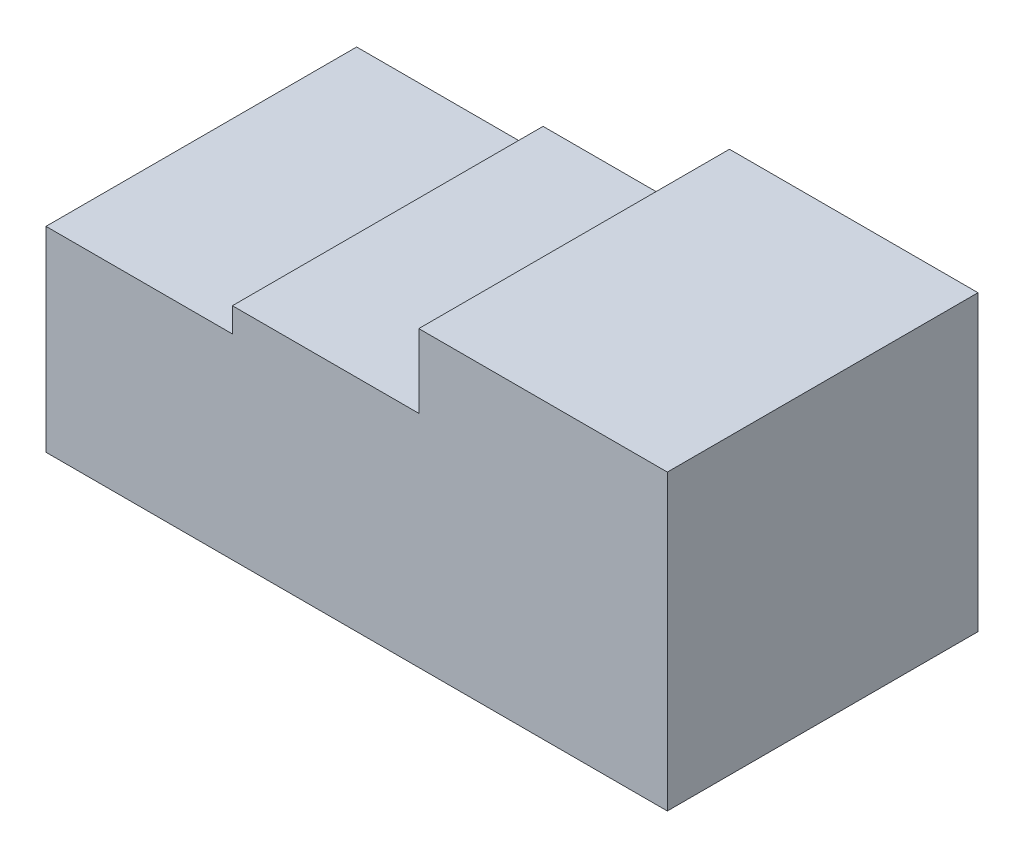
from build123d import *

# Parameters (mm, degrees)
BOSS_EXTRUDE1_DEPTH = 25.4
CUT_EXTRUDE1_DEPTH  = 4


with BuildPart() as part:
    # Sketch1 → Boss-Extrude1 (new body)
    with BuildSketch(Plane.XY):
        Polygon((0, 0), (50.8, 0), (50.8, 24), (30.48, 24), (30.48, 18), (15.24, 18), (15.24, 16), (0, 16), align=None)
    extrude(amount=BOSS_EXTRUDE1_DEPTH)

    # Sketch2 → Cut-Extrude1 (cut)
    with BuildSketch(Plane(origin=(0, 0, 0), x_dir=(-1, 0, 0), z_dir=(0, 0, -1))):
        with BuildLine():
            Line((-11.295583304, 12.778087276), (-11.533029885, 12.778087276))
            add(Edge.make_bspline(
                [(-11.533029885, 12.778087276), (-11.531572522, 12.809575531), (-11.528713289, 12.871353046), (-11.516252525, 12.961529656), (-11.498058527, 13.047711984), (-11.471773606, 13.129079663), (-11.439991974, 13.206785318), (-11.401253164, 13.279890085), (-11.355949163, 13.348858041), (-11.304136805, 13.412465116), (-11.247954919, 13.47053484), (-11.18779932, 13.52151142), (-11.123831636, 13.563773065), (-11.057192589, 13.599493121), (-10.986884509, 13.626239523), (-10.913640661, 13.646190792), (-10.836980782, 13.658076885), (-10.78469055, 13.659373545), (-10.758148408, 13.66003172)],
                knots=[0, 0, 0, 0, 9.4523e-05, 0.000185446, 0.000272771, 0.000358426, 0.000441598, 0.000524343, 0.000606223, 0.00068875, 0.000770085, 0.00084833, 0.000924769, 0.000999689, 0.001074691, 0.001149905, 0.001227113, 0.001306701, 0.001306701, 0.001306701, 0.001306701], degree=3))
            add(Edge.make_bspline(
                [(-10.758148408, 13.66003172), (-10.731960548, 13.659353685), (-10.68075122, 13.658027815), (-10.605918747, 13.646621805), (-10.535108463, 13.627947117), (-10.467619701, 13.602640908), (-10.404252866, 13.568846187), (-10.344773135, 13.527866845), (-10.288939132, 13.479696149), (-10.23838045, 13.424133521), (-10.191934607, 13.364315847), (-10.151617833, 13.300822017), (-10.116730428, 13.235148299), (-10.089311606, 13.166208706), (-10.067526922, 13.094945266), (-10.051368254, 13.021090543), (-10.042459589, 12.944378809), (-10.041164921, 12.892415422), (-10.040508518, 12.866069714)],
                knots=[0, 0, 0, 0, 7.853e-05, 0.000153562, 0.000226454, 0.000297918, 0.000369283, 0.00044132, 0.000514216, 0.00058998, 0.00066631, 0.000741147, 0.000815351, 0.000889069, 0.000963341, 0.001038709, 0.001115561, 0.001194597, 0.001194597, 0.001194597, 0.001194597], degree=3))
            add(Edge.make_bspline(
                [(-10.040508518, 12.866069714), (-10.041600283, 12.828898688), (-10.043759812, 12.75537383), (-10.06186439, 12.647089025), (-10.091127397, 12.542404939), (-10.125567065, 12.457517477), (-10.160444917, 12.388910391), (-10.192162361, 12.333062131), (-10.229680183, 12.273032827), (-10.272096757, 12.208237561), (-10.320151973, 12.139119815), (-10.374110374, 12.065918137), (-10.43269698, 11.987842672), (-10.47463475, 11.935084753), (-10.496321151, 11.907803155)],
                knots=[0, 0, 0, 0, 0.000111456, 0.000220461, 0.000328356, 0.000437015, 0.000494613, 0.000559171, 0.000629623, 0.000706947, 0.000791487, 0.000882126, 0.000979755, 0.001084302, 0.001084302, 0.001084302, 0.001084302], degree=3))
            Line((-10.496321151, 11.907803155), (-11.057076694, 11.217724028))
            Line((-11.057076694, 11.217724028), (-10.006587578, 11.217724028))
            Line((-10.006587578, 11.217724028), (-10.006587578, 10.946356507))
            Line((-10.006587578, 10.946356507), (-11.600871766, 10.946356507))
            Line((-11.600871766, 10.946356507), (-10.711507116, 12.041366857))
            add(Edge.make_bspline(
                [(-10.711507116, 12.041366857), (-10.689889178, 12.067461588), (-10.648310171, 12.117651067), (-10.589446671, 12.190781158), (-10.536471996, 12.258650576), (-10.488923601, 12.320987829), (-10.448459073, 12.37880704), (-10.412977585, 12.430799132), (-10.383874899, 12.477880644), (-10.352677075, 12.533205057), (-10.322859658, 12.600627754), (-10.296292224, 12.682346992), (-10.281243445, 12.76675858), (-10.279057625, 12.823612348), (-10.277955099, 12.852289332)],
                knots=[0, 0, 0, 0, 0.000101658, 0.000195524, 0.000281615, 0.000359952, 0.000430685, 0.000493307, 0.000548759, 0.000596686, 0.000683759, 0.000769413, 0.000853939, 0.000939964, 0.000939964, 0.000939964, 0.000939964], degree=3))
            add(Edge.make_bspline(
                [(-10.277955099, 12.852289332), (-10.278300298, 12.870334022), (-10.278979807, 12.905854207), (-10.286201362, 12.957984673), (-10.29734004, 13.008161489), (-10.312674236, 13.056705441), (-10.332798191, 13.103194264), (-10.357460674, 13.147764754), (-10.386871816, 13.190111323), (-10.419756558, 13.230595612), (-10.456162818, 13.267473966), (-10.494798891, 13.300131193), (-10.535915275, 13.327124737), (-10.57873842, 13.349822092), (-10.623730969, 13.367310401), (-10.670728194, 13.379374645), (-10.719554516, 13.387137812), (-10.752818161, 13.388148139), (-10.769808732, 13.388664199)],
                knots=[0, 0, 0, 0, 5.4103e-05, 0.0001065, 0.000157549, 0.00020817, 0.000258974, 0.00030927, 0.000360725, 0.000413456, 0.000465551, 0.000515972, 0.000564923, 0.000612812, 0.00066114, 0.000709348, 0.000758147, 0.000809097, 0.000809097, 0.000809097, 0.000809097], degree=3))
            add(Edge.make_bspline(
                [(-10.769808732, 13.388664199), (-10.787500652, 13.388123771), (-10.822335055, 13.387059699), (-10.873542848, 13.379570538), (-10.922401386, 13.36686802), (-10.96898922, 13.348997667), (-11.013648099, 13.327153673), (-11.055409027, 13.29880625), (-11.095110374, 13.266095738), (-11.13213107, 13.228364109), (-11.16621748, 13.18642825), (-11.196444173, 13.140011166), (-11.223038496, 13.089674595), (-11.245042687, 13.034977559), (-11.264647474, 12.976780446), (-11.278142964, 12.913913307), (-11.28992575, 12.847511354), (-11.293664514, 12.801632832), (-11.295583304, 12.778087276)],
                knots=[0, 0, 0, 0, 5.3068e-05, 0.000104487, 0.000154881, 0.000204198, 0.000253974, 0.00030366, 0.000355235, 0.00040808, 0.000461967, 0.000517093, 0.000573993, 0.000632458, 0.000693803, 0.000757961, 0.000825141, 0.000895969, 0.000895969, 0.000895969, 0.000895969], degree=3))
        make_face()
        with BuildLine():
            Line((-9.212837578, 12.879850096), (-8.975390997, 12.879850096))
            Line((-8.975390997, 12.879850096), (-8.975390997, 12.543820783))
            add(Edge.make_bspline(
                [(-8.975390997, 12.543820783), (-8.956794863, 12.573133728), (-8.921396056, 12.628932602), (-8.86334048, 12.703336958), (-8.805369343, 12.76630988), (-8.76293803, 12.799770446), (-8.742714548, 12.815718319)],
                knots=[0, 0, 0, 0, 0.000104077, 0.000198117, 0.000282847, 0.000360005, 0.000360005, 0.000360005, 0.000360005], degree=3))
            add(Edge.make_bspline(
                [(-8.742714548, 12.815718319), (-8.715341212, 12.830802884), (-8.661452156, 12.86049941), (-8.575012152, 12.891277549), (-8.486453749, 12.909838039), (-8.426560003, 12.912460091), (-8.396614955, 12.913771037)],
                knots=[0, 0, 0, 0, 9.3634e-05, 0.000184335, 0.000274144, 0.000363942, 0.000363942, 0.000363942, 0.000363942], degree=3))
            add(Edge.make_bspline(
                [(-8.396614955, 12.913771037), (-8.376436106, 12.912978178), (-8.336361145, 12.911403571), (-8.276845975, 12.901149854), (-8.219046141, 12.883587769), (-8.163490475, 12.859141435), (-8.111433351, 12.829017948), (-8.063281018, 12.794641861), (-8.020511278, 12.755134056), (-7.982695588, 12.709921892), (-7.947914792, 12.657930518), (-7.917233461, 12.596389434), (-7.887756651, 12.525440703), (-7.87148733, 12.474007075), (-7.862890162, 12.446828095)],
                knots=[0, 0, 0, 0, 6.0535e-05, 0.000120223, 0.000180584, 0.000241342, 0.000301889, 0.00036073, 0.000418489, 0.000476037, 0.000537189, 0.000605694, 0.000681976, 0.000767454, 0.000767454, 0.000767454, 0.000767454], degree=3))
            add(Edge.make_bspline(
                [(-7.862890162, 12.446828095), (-7.853733646, 12.465487304), (-7.835790121, 12.502052738), (-7.805821282, 12.554110694), (-7.774736964, 12.602909572), (-7.741736659, 12.648313537), (-7.706832704, 12.689915472), (-7.670597484, 12.728556798), (-7.632529649, 12.763495077), (-7.580053264, 12.804673494), (-7.511506355, 12.848069456), (-7.42462161, 12.886162824), (-7.334093444, 12.909555469), (-7.272588507, 12.912362103), (-7.241712945, 12.913771037)],
                knots=[0, 0, 0, 0, 6.2339e-05, 0.000122163, 0.00018009, 0.000235852, 0.000290413, 0.000342903, 0.000394671, 0.000445248, 0.000542892, 0.000637124, 0.000728907, 0.000821428, 0.000821428, 0.000821428, 0.000821428], degree=3))
            add(Edge.make_bspline(
                [(-7.241712945, 12.913771037), (-7.213348741, 12.912536714), (-7.1575831, 12.910109966), (-7.076395577, 12.891243943), (-7.000828388, 12.858848766), (-6.93110531, 12.814565774), (-6.868239825, 12.759187197), (-6.813920596, 12.693146875), (-6.767682626, 12.617486169), (-6.737905279, 12.546393548), (-6.717480464, 12.483563244), (-6.704532977, 12.430014174), (-6.693358447, 12.370934135), (-6.684749698, 12.306317237), (-6.676946357, 12.23620271), (-6.67274887, 12.160303458), (-6.669266146, 12.078853329), (-6.66893684, 12.022644258), (-6.668767065, 11.993665534)],
                knots=[0, 0, 0, 0, 8.5041e-05, 0.000167195, 0.000248411, 0.000330606, 0.000413972, 0.000498663, 0.000586199, 0.000679038, 0.000729155, 0.000784302, 0.000844177, 0.000909464, 0.000979818, 0.00105576, 0.001137444, 0.001224373, 0.001224373, 0.001224373, 0.001224373], degree=3))
            Line((-6.668767065, 11.993665534), (-6.668767065, 10.946356507))
            Line((-6.668767065, 10.946356507), (-6.906213646, 10.946356507))
            Line((-6.906213646, 10.946356507), (-6.906213646, 11.994725564))
            add(Edge.make_bspline(
                [(-6.906213646, 11.994725564), (-6.906323922, 12.019459768), (-6.906535835, 12.066990354), (-6.907895866, 12.135215362), (-6.911201131, 12.197409514), (-6.915274704, 12.253447893), (-6.920583511, 12.303470184), (-6.926647684, 12.347584604), (-6.934486566, 12.385644655), (-6.94632021, 12.427888082), (-6.965277061, 12.474283423), (-6.993540202, 12.52499537), (-7.03057646, 12.56865378), (-7.072705078, 12.607181187), (-7.12115953, 12.637925739), (-7.17441099, 12.660599309), (-7.232383819, 12.674152829), (-7.272557976, 12.675589155), (-7.29312437, 12.676324455)],
                knots=[0, 0, 0, 0, 7.4204e-05, 0.000142594, 0.000204688, 0.000261029, 0.000311131, 0.00035558, 0.00039456, 0.000427613, 0.00048706, 0.000544517, 0.000600978, 0.000658023, 0.000715218, 0.000772216, 0.000830971, 0.000892599, 0.000892599, 0.000892599, 0.000892599], degree=3))
            add(Edge.make_bspline(
                [(-7.29312437, 12.676324455), (-7.31835614, 12.675205627), (-7.368760594, 12.672970592), (-7.442062722, 12.651553709), (-7.512361665, 12.618349634), (-7.577347671, 12.571193799), (-7.637362534, 12.514442585), (-7.688536378, 12.446970825), (-7.731620204, 12.371322028), (-7.760118798, 12.301065578), (-7.778119859, 12.238059384), (-7.790227045, 12.182850773), (-7.800125402, 12.12019193), (-7.807819073, 12.050129329), (-7.814090775, 11.972712678), (-7.818918632, 11.887891904), (-7.821368935, 11.795631152), (-7.821836335, 11.731662799), (-7.822079031, 11.698447352)],
                knots=[0, 0, 0, 0, 7.553e-05, 0.000150884, 0.000227221, 0.000307811, 0.000390658, 0.000474193, 0.000560839, 0.000651191, 0.000700843, 0.000757296, 0.000820643, 0.000891056, 0.000968699, 0.001053635, 0.001145896, 0.001245544, 0.001245544, 0.001245544, 0.001245544], degree=3))
            Line((-7.822079031, 11.698447352), (-7.822079031, 10.946356507))
            Line((-7.822079031, 10.946356507), (-8.059525612, 10.946356507))
            Line((-8.059525612, 10.946356507), (-8.059525612, 11.929533757))
            add(Edge.make_bspline(
                [(-8.059525612, 11.929533757), (-8.059636013, 11.957271414), (-8.059848396, 12.010631616), (-8.061208209, 12.087156237), (-8.064486102, 12.156773514), (-8.068633125, 12.219335773), (-8.073749803, 12.274861778), (-8.080189574, 12.323462411), (-8.087051775, 12.365201937), (-8.099117964, 12.410866302), (-8.117764387, 12.460708), (-8.14634583, 12.514711133), (-8.182932637, 12.561799978), (-8.225999451, 12.602291257), (-8.274663903, 12.635073948), (-8.328121157, 12.659853106), (-8.386575312, 12.673504301), (-8.42693662, 12.675372705), (-8.447496365, 12.676324455)],
                knots=[0, 0, 0, 0, 8.3214e-05, 0.000160083, 0.000229587, 0.000292273, 0.000348176, 0.000396825, 0.000439348, 0.000474958, 0.000538356, 0.000598592, 0.000657536, 0.000716405, 0.000775206, 0.000832844, 0.000892236, 0.000953903, 0.000953903, 0.000953903, 0.000953903], degree=3))
            add(Edge.make_bspline(
                [(-8.447496365, 12.676324455), (-8.471840182, 12.675167813), (-8.520450463, 12.672858203), (-8.591624027, 12.651881364), (-8.660213005, 12.619019567), (-8.725577557, 12.574067271), (-8.785263505, 12.517824514), (-8.837524577, 12.452120179), (-8.881383168, 12.3773964), (-8.910463868, 12.308138804), (-8.929067008, 12.246684664), (-8.941938086, 12.194373202), (-8.9523179, 12.136111455), (-8.960507406, 12.072047975), (-8.967563679, 12.002256254), (-8.972142958, 11.926760161), (-8.974700016, 11.845279432), (-8.975154982, 11.789081766), (-8.975390997, 11.759929056)],
                knots=[0, 0, 0, 0, 7.289e-05, 0.000145548, 0.0002207, 0.000300381, 0.000382499, 0.000465853, 0.000551389, 0.000641655, 0.000690442, 0.000743919, 0.000803176, 0.000867866, 0.000937639, 0.001013581, 0.001094717, 0.001182176, 0.001182176, 0.001182176, 0.001182176], degree=3))
            Line((-8.975390997, 11.759929056), (-8.975390997, 10.946356507))
            Line((-8.975390997, 10.946356507), (-9.212837578, 10.946356507))
            Line((-9.212837578, 10.946356507), (-9.212837578, 12.879850096))
        make_face()
        with BuildLine():
            Line((-6.390615356, 12.879850096), (-6.153168774, 12.879850096))
            Line((-6.153168774, 12.879850096), (-6.153168774, 12.543820783))
            add(Edge.make_bspline(
                [(-6.153168774, 12.543820783), (-6.134572641, 12.573133728), (-6.099173834, 12.628932602), (-6.041118258, 12.703336958), (-5.983147121, 12.76630988), (-5.940715807, 12.799770446), (-5.920492325, 12.815718319)],
                knots=[0, 0, 0, 0, 0.000104077, 0.000198117, 0.000282847, 0.000360005, 0.000360005, 0.000360005, 0.000360005], degree=3))
            add(Edge.make_bspline(
                [(-5.920492325, 12.815718319), (-5.89311899, 12.830802884), (-5.839229934, 12.86049941), (-5.75278993, 12.891277549), (-5.664231527, 12.909838039), (-5.604337781, 12.912460091), (-5.574392733, 12.913771037)],
                knots=[0, 0, 0, 0, 9.3634e-05, 0.000184335, 0.000274144, 0.000363942, 0.000363942, 0.000363942, 0.000363942], degree=3))
            add(Edge.make_bspline(
                [(-5.574392733, 12.913771037), (-5.554213884, 12.912978178), (-5.514138923, 12.911403571), (-5.454623753, 12.901149854), (-5.396823918, 12.883587769), (-5.341268253, 12.859141435), (-5.289211129, 12.829017948), (-5.241058796, 12.794641861), (-5.198289056, 12.755134056), (-5.160473366, 12.709921892), (-5.12569257, 12.657930518), (-5.095011239, 12.596389434), (-5.065534429, 12.525440703), (-5.049265108, 12.474007075), (-5.04066794, 12.446828095)],
                knots=[0, 0, 0, 0, 6.0535e-05, 0.000120223, 0.000180584, 0.000241342, 0.000301889, 0.00036073, 0.000418489, 0.000476037, 0.000537189, 0.000605694, 0.000681976, 0.000767454, 0.000767454, 0.000767454, 0.000767454], degree=3))
            add(Edge.make_bspline(
                [(-5.04066794, 12.446828095), (-5.031511424, 12.465487304), (-5.013567899, 12.502052738), (-4.98359906, 12.554110694), (-4.952514742, 12.602909572), (-4.919514436, 12.648313537), (-4.884610482, 12.689915472), (-4.848375262, 12.728556798), (-4.810307427, 12.763495077), (-4.757831041, 12.804673494), (-4.689284133, 12.848069456), (-4.602399388, 12.886162824), (-4.511871222, 12.909555469), (-4.450366285, 12.912362103), (-4.419490723, 12.913771037)],
                knots=[0, 0, 0, 0, 6.2339e-05, 0.000122163, 0.00018009, 0.000235852, 0.000290413, 0.000342903, 0.000394671, 0.000445248, 0.000542892, 0.000637124, 0.000728907, 0.000821428, 0.000821428, 0.000821428, 0.000821428], degree=3))
            add(Edge.make_bspline(
                [(-4.419490723, 12.913771037), (-4.391126519, 12.912536714), (-4.335360878, 12.910109966), (-4.254173355, 12.891243943), (-4.178606166, 12.858848766), (-4.108883088, 12.814565774), (-4.046017603, 12.759187197), (-3.991698374, 12.693146875), (-3.945460404, 12.617486169), (-3.915683057, 12.546393548), (-3.895258242, 12.483563244), (-3.882310755, 12.430014174), (-3.871136225, 12.370934135), (-3.862527475, 12.306317237), (-3.854724135, 12.23620271), (-3.850526648, 12.160303458), (-3.847043924, 12.078853329), (-3.846714618, 12.022644258), (-3.846544843, 11.993665534)],
                knots=[0, 0, 0, 0, 8.5041e-05, 0.000167195, 0.000248411, 0.000330606, 0.000413972, 0.000498663, 0.000586199, 0.000679038, 0.000729155, 0.000784302, 0.000844177, 0.000909464, 0.000979818, 0.00105576, 0.001137444, 0.001224373, 0.001224373, 0.001224373, 0.001224373], degree=3))
            Line((-3.846544843, 11.993665534), (-3.846544843, 10.946356507))
            Line((-3.846544843, 10.946356507), (-4.083991424, 10.946356507))
            Line((-4.083991424, 10.946356507), (-4.083991424, 11.994725564))
            add(Edge.make_bspline(
                [(-4.083991424, 11.994725564), (-4.0841017, 12.019459768), (-4.084313613, 12.066990354), (-4.085673644, 12.135215362), (-4.088978909, 12.197409514), (-4.093052481, 12.253447893), (-4.098361288, 12.303470184), (-4.104425462, 12.347584604), (-4.112264344, 12.385644655), (-4.124097987, 12.427888082), (-4.143054839, 12.474283423), (-4.17131798, 12.52499537), (-4.208354238, 12.56865378), (-4.250482856, 12.607181187), (-4.298937308, 12.637925739), (-4.352188768, 12.660599309), (-4.410161597, 12.674152829), (-4.450335754, 12.675589155), (-4.470902148, 12.676324455)],
                knots=[0, 0, 0, 0, 7.4204e-05, 0.000142594, 0.000204688, 0.000261029, 0.000311131, 0.00035558, 0.00039456, 0.000427613, 0.00048706, 0.000544517, 0.000600978, 0.000658023, 0.000715218, 0.000772216, 0.000830971, 0.000892599, 0.000892599, 0.000892599, 0.000892599], degree=3))
            add(Edge.make_bspline(
                [(-4.470902148, 12.676324455), (-4.496133918, 12.675205627), (-4.546538372, 12.672970592), (-4.6198405, 12.651553709), (-4.690139443, 12.618349634), (-4.755125449, 12.571193799), (-4.815140312, 12.514442585), (-4.866314156, 12.446970825), (-4.909397982, 12.371322028), (-4.937896576, 12.301065578), (-4.955897637, 12.238059384), (-4.968004823, 12.182850773), (-4.977903179, 12.12019193), (-4.985596851, 12.050129329), (-4.991868553, 11.972712678), (-4.99669641, 11.887891904), (-4.999146713, 11.795631152), (-4.999614112, 11.731662799), (-4.999856809, 11.698447352)],
                knots=[0, 0, 0, 0, 7.553e-05, 0.000150884, 0.000227221, 0.000307811, 0.000390658, 0.000474193, 0.000560839, 0.000651191, 0.000700843, 0.000757296, 0.000820643, 0.000891056, 0.000968699, 0.001053635, 0.001145896, 0.001245544, 0.001245544, 0.001245544, 0.001245544], degree=3))
            Line((-4.999856809, 11.698447352), (-4.999856809, 10.946356507))
            Line((-4.999856809, 10.946356507), (-5.23730339, 10.946356507))
            Line((-5.23730339, 10.946356507), (-5.23730339, 11.929533757))
            add(Edge.make_bspline(
                [(-5.23730339, 11.929533757), (-5.237413791, 11.957271414), (-5.237626174, 12.010631616), (-5.238985986, 12.087156237), (-5.24226388, 12.156773514), (-5.246410903, 12.219335773), (-5.251527581, 12.274861778), (-5.257967352, 12.323462411), (-5.264829553, 12.365201937), (-5.276895741, 12.410866302), (-5.295542164, 12.460708), (-5.324123608, 12.514711133), (-5.360710415, 12.561799978), (-5.403777229, 12.602291257), (-5.452441681, 12.635073948), (-5.505898935, 12.659853106), (-5.564353089, 12.673504301), (-5.604714398, 12.675372705), (-5.625274143, 12.676324455)],
                knots=[0, 0, 0, 0, 8.3214e-05, 0.000160083, 0.000229587, 0.000292273, 0.000348176, 0.000396825, 0.000439348, 0.000474958, 0.000538356, 0.000598592, 0.000657536, 0.000716405, 0.000775206, 0.000832844, 0.000892236, 0.000953903, 0.000953903, 0.000953903, 0.000953903], degree=3))
            add(Edge.make_bspline(
                [(-5.625274143, 12.676324455), (-5.649617959, 12.675167813), (-5.698228241, 12.672858203), (-5.769401805, 12.651881364), (-5.837990783, 12.619019567), (-5.903355334, 12.574067271), (-5.963041282, 12.517824514), (-6.015302355, 12.452120179), (-6.059160946, 12.3773964), (-6.088241645, 12.308138804), (-6.106844786, 12.246684664), (-6.119715864, 12.194373202), (-6.130095678, 12.136111455), (-6.138285184, 12.072047975), (-6.145341456, 12.002256254), (-6.149920736, 11.926760161), (-6.152477794, 11.845279432), (-6.15293276, 11.789081766), (-6.153168774, 11.759929056)],
                knots=[0, 0, 0, 0, 7.289e-05, 0.000145548, 0.0002207, 0.000300381, 0.000382499, 0.000465853, 0.000551389, 0.000641655, 0.000690442, 0.000743919, 0.000803176, 0.000867866, 0.000937639, 0.001013581, 0.001094717, 0.001182176, 0.001182176, 0.001182176, 0.001182176], degree=3))
            Line((-6.153168774, 11.759929056), (-6.153168774, 10.946356507))
            Line((-6.153168774, 10.946356507), (-6.390615356, 10.946356507))
            Line((-6.390615356, 10.946356507), (-6.390615356, 12.879850096))
        make_face()
        Polygon((-26.740842964, 16.044593311), (-26.692611627, 16.044593311), (-26.692611627, 14.212862541), (-26.421244106, 14.212862541), (-26.421244106, 13.94149502), (-26.692611627, 13.94149502), (-26.692611627, 13.330918097), (-26.930058208, 13.330918097), (-26.930058208, 13.94149502), (-28.015528294, 13.94149502), align=None)
        Polygon((-26.930058208, 14.212862541), (-26.930058208, 15.257521496), (-27.562895749, 14.212862541), align=None, mode=Mode.SUBTRACT)
        with BuildLine():
            Line((-25.627494106, 15.264411687), (-25.390047525, 15.264411687))
            Line((-25.390047525, 15.264411687), (-25.390047525, 14.928382373))
            add(Edge.make_bspline(
                [(-25.390047525, 14.928382373), (-25.371451391, 14.957695318), (-25.336052584, 15.013494192), (-25.277997009, 15.087898548), (-25.220025871, 15.15087147), (-25.177594558, 15.184332037), (-25.157371076, 15.200279909)],
                knots=[0, 0, 0, 0, 0.000104077, 0.000198117, 0.000282847, 0.000360005, 0.000360005, 0.000360005, 0.000360005], degree=3))
            add(Edge.make_bspline(
                [(-25.157371076, 15.200279909), (-25.12999774, 15.215364474), (-25.076108684, 15.245061), (-24.98966868, 15.275839139), (-24.901110278, 15.294399629), (-24.841216531, 15.297021681), (-24.811271483, 15.298332627)],
                knots=[0, 0, 0, 0, 9.3634e-05, 0.000184335, 0.000274144, 0.000363942, 0.000363942, 0.000363942, 0.000363942], degree=3))
            add(Edge.make_bspline(
                [(-24.811271483, 15.298332627), (-24.791092634, 15.297539769), (-24.751017673, 15.295965161), (-24.691502504, 15.285711444), (-24.633702669, 15.268149359), (-24.578147003, 15.243703025), (-24.52608988, 15.213579538), (-24.477937547, 15.179203451), (-24.435167806, 15.139695646), (-24.397352116, 15.094483482), (-24.36257132, 15.042492108), (-24.33188999, 14.980951024), (-24.302413179, 14.910002293), (-24.286143858, 14.858568665), (-24.27754669, 14.831389685)],
                knots=[0, 0, 0, 0, 6.0535e-05, 0.000120223, 0.000180584, 0.000241342, 0.000301889, 0.00036073, 0.000418489, 0.000476037, 0.000537189, 0.000605694, 0.000681976, 0.000767454, 0.000767454, 0.000767454, 0.000767454], degree=3))
            add(Edge.make_bspline(
                [(-24.27754669, 14.831389685), (-24.268390174, 14.850048894), (-24.250446649, 14.886614329), (-24.22047781, 14.938672284), (-24.189393492, 14.987471162), (-24.156393187, 15.032875127), (-24.121489232, 15.074477063), (-24.085254012, 15.113118388), (-24.047186177, 15.148056667), (-23.994709792, 15.189235084), (-23.926162883, 15.232631046), (-23.839278138, 15.270724414), (-23.748749972, 15.294117059), (-23.687245035, 15.296923693), (-23.656369473, 15.298332627)],
                knots=[0, 0, 0, 0, 6.2339e-05, 0.000122163, 0.00018009, 0.000235852, 0.000290413, 0.000342903, 0.000394671, 0.000445248, 0.000542892, 0.000637124, 0.000728907, 0.000821428, 0.000821428, 0.000821428, 0.000821428], degree=3))
            add(Edge.make_bspline(
                [(-23.656369473, 15.298332627), (-23.628005269, 15.297098304), (-23.572239628, 15.294671556), (-23.491052105, 15.275805534), (-23.415484916, 15.243410356), (-23.345761838, 15.199127365), (-23.282896353, 15.143748787), (-23.228577124, 15.077708465), (-23.182339154, 15.002047759), (-23.152561807, 14.930955138), (-23.132136992, 14.868124834), (-23.119189505, 14.814575765), (-23.108014975, 14.755495725), (-23.099406226, 14.690878828), (-23.091602885, 14.620764301), (-23.087405398, 14.544865048), (-23.083922674, 14.46341492), (-23.083593368, 14.407205848), (-23.083423593, 14.378227125)],
                knots=[0, 0, 0, 0, 8.5041e-05, 0.000167195, 0.000248411, 0.000330606, 0.000413972, 0.000498663, 0.000586199, 0.000679038, 0.000729155, 0.000784302, 0.000844177, 0.000909464, 0.000979818, 0.00105576, 0.001137444, 0.001224373, 0.001224373, 0.001224373, 0.001224373], degree=3))
            Line((-23.083423593, 14.378227125), (-23.083423593, 13.330918097))
            Line((-23.083423593, 13.330918097), (-23.320870174, 13.330918097))
            Line((-23.320870174, 13.330918097), (-23.320870174, 14.379287154))
            add(Edge.make_bspline(
                [(-23.320870174, 14.379287154), (-23.320980451, 14.404021358), (-23.321192363, 14.451551944), (-23.322552394, 14.519776952), (-23.32585766, 14.581971105), (-23.329931232, 14.638009483), (-23.335240039, 14.688031774), (-23.341304212, 14.732146194), (-23.349143094, 14.770206245), (-23.360976738, 14.812449672), (-23.37993359, 14.858845014), (-23.40819673, 14.90955696), (-23.445232988, 14.95321537), (-23.487361607, 14.991742777), (-23.535816058, 15.02248733), (-23.589067518, 15.0451609), (-23.647040347, 15.058714419), (-23.687214505, 15.060150746), (-23.707780898, 15.060886046)],
                knots=[0, 0, 0, 0, 7.4204e-05, 0.000142594, 0.000204688, 0.000261029, 0.000311131, 0.00035558, 0.00039456, 0.000427613, 0.00048706, 0.000544517, 0.000600978, 0.000658023, 0.000715218, 0.000772216, 0.000830971, 0.000892599, 0.000892599, 0.000892599, 0.000892599], degree=3))
            add(Edge.make_bspline(
                [(-23.707780898, 15.060886046), (-23.733012668, 15.059767218), (-23.783417122, 15.057532182), (-23.85671925, 15.036115299), (-23.927018193, 15.002911225), (-23.992004199, 14.955755389), (-24.052019062, 14.899004176), (-24.103192906, 14.831532416), (-24.146276732, 14.755883618), (-24.174775326, 14.685627168), (-24.192776387, 14.622620975), (-24.204883573, 14.567412363), (-24.21478193, 14.50475352), (-24.222475601, 14.43469092), (-24.228747303, 14.357274268), (-24.23357516, 14.272453495), (-24.236025463, 14.180192742), (-24.236492863, 14.116224389), (-24.236735559, 14.083008942)],
                knots=[0, 0, 0, 0, 7.553e-05, 0.000150884, 0.000227221, 0.000307811, 0.000390658, 0.000474193, 0.000560839, 0.000651191, 0.000700843, 0.000757296, 0.000820643, 0.000891056, 0.000968699, 0.001053635, 0.001145896, 0.001245544, 0.001245544, 0.001245544, 0.001245544], degree=3))
            Line((-24.236735559, 14.083008942), (-24.236735559, 13.330918097))
            Line((-24.236735559, 13.330918097), (-24.47418214, 13.330918097))
            Line((-24.47418214, 13.330918097), (-24.47418214, 14.314095347))
            add(Edge.make_bspline(
                [(-24.47418214, 14.314095347), (-24.474292541, 14.341833005), (-24.474504924, 14.395193206), (-24.475864737, 14.471717827), (-24.47914263, 14.541335104), (-24.483289653, 14.603897363), (-24.488406331, 14.659423369), (-24.494846102, 14.708024001), (-24.501708303, 14.749763527), (-24.513774492, 14.795427893), (-24.532420915, 14.84526959), (-24.561002358, 14.899272723), (-24.597589165, 14.946361568), (-24.640655979, 14.986852847), (-24.689320432, 15.019635538), (-24.742777685, 15.044414697), (-24.80123184, 15.058065891), (-24.841593148, 15.059934295), (-24.862152893, 15.060886046)],
                knots=[0, 0, 0, 0, 8.3214e-05, 0.000160083, 0.000229587, 0.000292273, 0.000348176, 0.000396825, 0.000439348, 0.000474958, 0.000538356, 0.000598592, 0.000657536, 0.000716405, 0.000775206, 0.000832844, 0.000892236, 0.000953903, 0.000953903, 0.000953903, 0.000953903], degree=3))
            add(Edge.make_bspline(
                [(-24.862152893, 15.060886046), (-24.88649671, 15.059729403), (-24.935106991, 15.057419793), (-25.006280556, 15.036442954), (-25.074869533, 15.003581157), (-25.140234085, 14.958628861), (-25.199920033, 14.902386104), (-25.252181105, 14.83668177), (-25.296039696, 14.76195799), (-25.325120396, 14.692700394), (-25.343723536, 14.631246254), (-25.356594614, 14.578934792), (-25.366974428, 14.520673046), (-25.375163934, 14.456609566), (-25.382220207, 14.386817845), (-25.386799486, 14.311321751), (-25.389356544, 14.229841023), (-25.38981151, 14.173643356), (-25.390047525, 14.144490646)],
                knots=[0, 0, 0, 0, 7.289e-05, 0.000145548, 0.0002207, 0.000300381, 0.000382499, 0.000465853, 0.000551389, 0.000641655, 0.000690442, 0.000743919, 0.000803176, 0.000867866, 0.000937639, 0.001013581, 0.001094717, 0.001182176, 0.001182176, 0.001182176, 0.001182176], degree=3))
            Line((-25.390047525, 14.144490646), (-25.390047525, 13.330918097))
            Line((-25.390047525, 13.330918097), (-25.627494106, 13.330918097))
            Line((-25.627494106, 13.330918097), (-25.627494106, 15.264411687))
        make_face()
        with BuildLine():
            Line((-22.805271884, 15.264411687), (-22.567825302, 15.264411687))
            Line((-22.567825302, 15.264411687), (-22.567825302, 14.928382373))
            add(Edge.make_bspline(
                [(-22.567825302, 14.928382373), (-22.549229169, 14.957695318), (-22.513830362, 15.013494192), (-22.455774786, 15.087898548), (-22.397803649, 15.15087147), (-22.355372336, 15.184332037), (-22.335148854, 15.200279909)],
                knots=[0, 0, 0, 0, 0.000104077, 0.000198117, 0.000282847, 0.000360005, 0.000360005, 0.000360005, 0.000360005], degree=3))
            add(Edge.make_bspline(
                [(-22.335148854, 15.200279909), (-22.307775518, 15.215364474), (-22.253886462, 15.245061), (-22.167446458, 15.275839139), (-22.078888055, 15.294399629), (-22.018994309, 15.297021681), (-21.989049261, 15.298332627)],
                knots=[0, 0, 0, 0, 9.3634e-05, 0.000184335, 0.000274144, 0.000363942, 0.000363942, 0.000363942, 0.000363942], degree=3))
            add(Edge.make_bspline(
                [(-21.989049261, 15.298332627), (-21.968870412, 15.297539769), (-21.928795451, 15.295965161), (-21.869280281, 15.285711444), (-21.811480446, 15.268149359), (-21.755924781, 15.243703025), (-21.703867657, 15.213579538), (-21.655715324, 15.179203451), (-21.612945584, 15.139695646), (-21.575129894, 15.094483482), (-21.540349098, 15.042492108), (-21.509667767, 14.980951024), (-21.480190957, 14.910002293), (-21.463921636, 14.858568665), (-21.455324468, 14.831389685)],
                knots=[0, 0, 0, 0, 6.0535e-05, 0.000120223, 0.000180584, 0.000241342, 0.000301889, 0.00036073, 0.000418489, 0.000476037, 0.000537189, 0.000605694, 0.000681976, 0.000767454, 0.000767454, 0.000767454, 0.000767454], degree=3))
            add(Edge.make_bspline(
                [(-21.455324468, 14.831389685), (-21.446167952, 14.850048894), (-21.428224427, 14.886614329), (-21.398255588, 14.938672284), (-21.36717127, 14.987471162), (-21.334170965, 15.032875127), (-21.29926701, 15.074477063), (-21.26303179, 15.113118388), (-21.224963955, 15.148056667), (-21.172487569, 15.189235084), (-21.103940661, 15.232631046), (-21.017055916, 15.270724414), (-20.92652775, 15.294117059), (-20.865022813, 15.296923693), (-20.834147251, 15.298332627)],
                knots=[0, 0, 0, 0, 6.2339e-05, 0.000122163, 0.00018009, 0.000235852, 0.000290413, 0.000342903, 0.000394671, 0.000445248, 0.000542892, 0.000637124, 0.000728907, 0.000821428, 0.000821428, 0.000821428, 0.000821428], degree=3))
            add(Edge.make_bspline(
                [(-20.834147251, 15.298332627), (-20.805783047, 15.297098304), (-20.750017406, 15.294671556), (-20.668829883, 15.275805534), (-20.593262694, 15.243410356), (-20.523539616, 15.199127365), (-20.460674131, 15.143748787), (-20.406354902, 15.077708465), (-20.360116932, 15.002047759), (-20.330339585, 14.930955138), (-20.30991477, 14.868124834), (-20.296967283, 14.814575765), (-20.285792753, 14.755495725), (-20.277184003, 14.690878828), (-20.269380663, 14.620764301), (-20.265183176, 14.544865048), (-20.261700452, 14.46341492), (-20.261371146, 14.407205848), (-20.261201371, 14.378227125)],
                knots=[0, 0, 0, 0, 8.5041e-05, 0.000167195, 0.000248411, 0.000330606, 0.000413972, 0.000498663, 0.000586199, 0.000679038, 0.000729155, 0.000784302, 0.000844177, 0.000909464, 0.000979818, 0.00105576, 0.001137444, 0.001224373, 0.001224373, 0.001224373, 0.001224373], degree=3))
            Line((-20.261201371, 14.378227125), (-20.261201371, 13.330918097))
            Line((-20.261201371, 13.330918097), (-20.498647952, 13.330918097))
            Line((-20.498647952, 13.330918097), (-20.498647952, 14.379287154))
            add(Edge.make_bspline(
                [(-20.498647952, 14.379287154), (-20.498758228, 14.404021358), (-20.498970141, 14.451551944), (-20.500330172, 14.519776952), (-20.503635437, 14.581971105), (-20.50770901, 14.638009483), (-20.513017817, 14.688031774), (-20.51908199, 14.732146194), (-20.526920872, 14.770206245), (-20.538754515, 14.812449672), (-20.557711367, 14.858845014), (-20.585974508, 14.90955696), (-20.623010766, 14.95321537), (-20.665139384, 14.991742777), (-20.713593836, 15.02248733), (-20.766845296, 15.0451609), (-20.824818125, 15.058714419), (-20.864992282, 15.060150746), (-20.885558676, 15.060886046)],
                knots=[0, 0, 0, 0, 7.4204e-05, 0.000142594, 0.000204688, 0.000261029, 0.000311131, 0.00035558, 0.00039456, 0.000427613, 0.00048706, 0.000544517, 0.000600978, 0.000658023, 0.000715218, 0.000772216, 0.000830971, 0.000892599, 0.000892599, 0.000892599, 0.000892599], degree=3))
            add(Edge.make_bspline(
                [(-20.885558676, 15.060886046), (-20.910790446, 15.059767218), (-20.9611949, 15.057532182), (-21.034497028, 15.036115299), (-21.104795971, 15.002911225), (-21.169781977, 14.955755389), (-21.22979684, 14.899004176), (-21.280970684, 14.831532416), (-21.32405451, 14.755883618), (-21.352553104, 14.685627168), (-21.370554165, 14.622620975), (-21.382661351, 14.567412363), (-21.392559708, 14.50475352), (-21.400253379, 14.43469092), (-21.406525081, 14.357274268), (-21.411352938, 14.272453495), (-21.413803241, 14.180192742), (-21.41427064, 14.116224389), (-21.414513337, 14.083008942)],
                knots=[0, 0, 0, 0, 7.553e-05, 0.000150884, 0.000227221, 0.000307811, 0.000390658, 0.000474193, 0.000560839, 0.000651191, 0.000700843, 0.000757296, 0.000820643, 0.000891056, 0.000968699, 0.001053635, 0.001145896, 0.001245544, 0.001245544, 0.001245544, 0.001245544], degree=3))
            Line((-21.414513337, 14.083008942), (-21.414513337, 13.330918097))
            Line((-21.414513337, 13.330918097), (-21.651959918, 13.330918097))
            Line((-21.651959918, 13.330918097), (-21.651959918, 14.314095347))
            add(Edge.make_bspline(
                [(-21.651959918, 14.314095347), (-21.652070319, 14.341833005), (-21.652282702, 14.395193206), (-21.653642514, 14.471717827), (-21.656920408, 14.541335104), (-21.661067431, 14.603897363), (-21.666184109, 14.659423369), (-21.67262388, 14.708024001), (-21.679486081, 14.749763527), (-21.69155227, 14.795427893), (-21.710198692, 14.84526959), (-21.738780136, 14.899272723), (-21.775366943, 14.946361568), (-21.818433757, 14.986852847), (-21.867098209, 15.019635538), (-21.920555463, 15.044414697), (-21.979009618, 15.058065891), (-22.019370926, 15.059934295), (-22.039930671, 15.060886046)],
                knots=[0, 0, 0, 0, 8.3214e-05, 0.000160083, 0.000229587, 0.000292273, 0.000348176, 0.000396825, 0.000439348, 0.000474958, 0.000538356, 0.000598592, 0.000657536, 0.000716405, 0.000775206, 0.000832844, 0.000892236, 0.000953903, 0.000953903, 0.000953903, 0.000953903], degree=3))
            add(Edge.make_bspline(
                [(-22.039930671, 15.060886046), (-22.064274488, 15.059729403), (-22.112884769, 15.057419793), (-22.184058333, 15.036442954), (-22.252647311, 15.003581157), (-22.318011863, 14.958628861), (-22.377697811, 14.902386104), (-22.429958883, 14.83668177), (-22.473817474, 14.76195799), (-22.502898174, 14.692700394), (-22.521501314, 14.631246254), (-22.534372392, 14.578934792), (-22.544752206, 14.520673046), (-22.552941712, 14.456609566), (-22.559997984, 14.386817845), (-22.564577264, 14.311321751), (-22.567134322, 14.229841023), (-22.567589288, 14.173643356), (-22.567825302, 14.144490646)],
                knots=[0, 0, 0, 0, 7.289e-05, 0.000145548, 0.0002207, 0.000300381, 0.000382499, 0.000465853, 0.000551389, 0.000641655, 0.000690442, 0.000743919, 0.000803176, 0.000867866, 0.000937639, 0.001013581, 0.001094717, 0.001182176, 0.001182176, 0.001182176, 0.001182176], degree=3))
            Line((-22.567825302, 14.144490646), (-22.567825302, 13.330918097))
            Line((-22.567825302, 13.330918097), (-22.805271884, 13.330918097))
            Line((-22.805271884, 13.330918097), (-22.805271884, 15.264411687))
        make_face()
        Polygon((-45.557124184, 20.801329531), (-45.088591198, 20.801329531), (-45.088591198, 18.155496198), (-45.326037779, 18.155496198), (-45.326037779, 20.52996201), (-45.699168121, 20.52996201), align=None)
        with BuildLine():
            add(Edge.make_bspline(
                [(-44.471230087, 19.477352835), (-44.47096563, 19.519760342), (-44.470451964, 19.602130115), (-44.46532133, 19.722110341), (-44.458548581, 19.834780945), (-44.447074087, 19.939904737), (-44.433667125, 20.037579917), (-44.416763861, 20.127805929), (-44.39687256, 20.210697423), (-44.373264381, 20.28649503), (-44.347230693, 20.356638537), (-44.318097264, 20.421658807), (-44.28650301, 20.482360367), (-44.253634831, 20.539433786), (-44.216627856, 20.591217417), (-44.178216984, 20.639343658), (-44.136337292, 20.682386995), (-44.092699384, 20.721748136), (-44.046370411, 20.755919192), (-43.999205491, 20.786555899), (-43.950346169, 20.811972802), (-43.900117092, 20.832754984), (-43.84875401, 20.849298911), (-43.795888819, 20.860976451), (-43.741772799, 20.868077318), (-43.70520358, 20.868805246), (-43.686808345, 20.869171412)],
                knots=[0, 0, 0, 0, 0.000127213, 0.000247092, 0.000360228, 0.00046576, 0.000564251, 0.000655936, 0.000741036, 0.000819829, 0.000893959, 0.000965371, 0.001033405, 0.001099217, 0.001162741, 0.001224161, 0.001283761, 0.001342698, 0.001400258, 0.001456274, 0.001511273, 0.001565212, 0.001619185, 0.001672937, 0.001727436, 0.001782598, 0.001782598, 0.001782598, 0.001782598], degree=3))
            add(Edge.make_bspline(
                [(-43.686808345, 20.869171412), (-43.668058536, 20.868816203), (-43.630958091, 20.868113348), (-43.575982963, 20.860902763), (-43.522366165, 20.849410563), (-43.470207881, 20.832617504), (-43.41913417, 20.812155143), (-43.369611822, 20.786348073), (-43.321275508, 20.75620749), (-43.274776096, 20.720929217), (-43.229310342, 20.681922039), (-43.187132175, 20.63718402), (-43.147452354, 20.587929421), (-43.108694825, 20.535149811), (-43.074323954, 20.476408965), (-43.041070224, 20.41386463), (-43.01116307, 20.346200325), (-42.982748238, 20.274088194), (-42.957846654, 20.19618737), (-42.93621583, 20.112291407), (-42.9178036, 20.022053905), (-42.902428048, 19.925523488), (-42.890793743, 19.822415149), (-42.883400657, 19.712935052), (-42.877591484, 19.597197304), (-42.877164834, 19.51799541), (-42.876945899, 19.477352835)],
                knots=[0, 0, 0, 0, 5.6222e-05, 0.000111246, 0.000166033, 0.000220511, 0.000275431, 0.0003309, 0.000387812, 0.000446114, 0.000505846, 0.000567328, 0.000630239, 0.000695549, 0.00076354, 0.000834189, 0.00090797, 0.000985332, 0.001066625, 0.001153141, 0.001245133, 0.001342812, 0.001446294, 0.001556295, 0.00167196, 0.001793873, 0.001793873, 0.001793873, 0.001793873], degree=3))
            add(Edge.make_bspline(
                [(-42.876945899, 19.477352835), (-42.877247341, 19.436890956), (-42.877834652, 19.358057799), (-42.882502231, 19.242788304), (-42.89096548, 19.133900441), (-42.902535087, 19.03134985), (-42.917230213, 18.935300592), (-42.935316187, 18.845472631), (-42.955982678, 18.761745705), (-42.981364665, 18.684466472), (-43.008870373, 18.612601421), (-43.039143286, 18.545524681), (-43.072107103, 18.483004948), (-43.106856556, 18.424474088), (-43.144549261, 18.370749075), (-43.185043731, 18.321740355), (-43.22789457, 18.277237557), (-43.272994036, 18.237199734), (-43.320376412, 18.20253204), (-43.36843195, 18.171205061), (-43.418662455, 18.146064288), (-43.469669681, 18.124460343), (-43.522236427, 18.108043485), (-43.576018655, 18.096604084), (-43.630914281, 18.088539917), (-43.668051542, 18.087951505), (-43.686808345, 18.087654318)],
                knots=[0, 0, 0, 0, 0.000121384, 0.000236496, 0.000346008, 0.000448963, 0.000546037, 0.000637404, 0.000723788, 0.000804577, 0.000881253, 0.000954551, 0.0010252, 0.001093191, 0.001158625, 0.001221873, 0.001283721, 0.001343803, 0.001402529, 0.001459724, 0.001515665, 0.001570787, 0.00162577, 0.001680557, 0.001735651, 0.001791872, 0.001791872, 0.001791872, 0.001791872], degree=3))
            add(Edge.make_bspline(
                [(-43.686808345, 18.087654318), (-43.705203257, 18.088021936), (-43.741771833, 18.088752752), (-43.795892607, 18.095832256), (-43.848523325, 18.107541609), (-43.899685098, 18.123671404), (-43.949853311, 18.143513486), (-43.998056667, 18.169491899), (-44.045267684, 18.199088031), (-44.091083332, 18.232992999), (-44.134415567, 18.271942314), (-44.176056679, 18.314861183), (-44.214740907, 18.362976466), (-44.251085717, 18.415299053), (-44.28530138, 18.471831569), (-44.316560354, 18.53296977), (-44.344899016, 18.598833397), (-44.371718053, 18.669235407), (-44.395961583, 18.745510761), (-44.415504495, 18.829097832), (-44.43328559, 18.919535062), (-44.446494074, 19.01728636), (-44.457866046, 19.122063825), (-44.465520977, 19.234160081), (-44.470390296, 19.353462362), (-44.470945031, 19.435299885), (-44.471230087, 19.477352835)],
                knots=[0, 0, 0, 0, 5.5162e-05, 0.000109661, 0.000163413, 0.000216721, 0.000270459, 0.000324989, 0.000380721, 0.000437539, 0.000495727, 0.000555327, 0.000616747, 0.000680706, 0.000746333, 0.000814839, 0.000886522, 0.000961335, 0.001040791, 0.001126406, 0.001218711, 0.001317203, 0.001422207, 0.001534851, 0.0016542, 0.001780353, 0.001780353, 0.001780353, 0.001780353], degree=3))
        make_face()
        with BuildLine():
            add(Edge.make_bspline(
                [(-44.233783505, 19.478412865), (-44.233594223, 19.443075875), (-44.233226934, 19.374506863), (-44.229997857, 19.274836683), (-44.224882984, 19.181861565), (-44.217418645, 19.095613174), (-44.208248462, 19.015974614), (-44.19583578, 18.943039908), (-44.182468046, 18.876583284), (-44.166263935, 18.816494275), (-44.148385273, 18.76131601), (-44.127315153, 18.71046368), (-44.105454599, 18.66256155), (-44.080734414, 18.618557326), (-44.054947787, 18.577254216), (-44.026298275, 18.539888403), (-43.995941441, 18.505566916), (-43.953587167, 18.465465572), (-43.89806985, 18.423300557), (-43.827107311, 18.386590743), (-43.753951373, 18.363477881), (-43.704104405, 18.360498931), (-43.679388139, 18.359021839)],
                knots=[0, 0, 0, 0, 0.000106008, 0.000205702, 0.000299135, 0.000385317, 0.00046539, 0.000539541, 0.000607211, 0.000668665, 0.000726154, 0.000781074, 0.000833713, 0.000884009, 0.000932383, 0.000979661, 0.001025085, 0.001069698, 0.0011545, 0.0012332, 0.001308486, 0.001382531, 0.001382531, 0.001382531, 0.001382531], degree=3))
            add(Edge.make_bspline(
                [(-43.679388139, 18.359021839), (-43.654473785, 18.360223633), (-43.604558896, 18.362631379), (-43.53195381, 18.386343413), (-43.461368191, 18.421262404), (-43.40706528, 18.463144143), (-43.365494148, 18.50238769), (-43.335494936, 18.536236471), (-43.307562221, 18.573584344), (-43.282242695, 18.614842867), (-43.258121563, 18.659139512), (-43.235982261, 18.707047588), (-43.21640478, 18.758895452), (-43.205031038, 18.7948137), (-43.19919483, 18.813244429)],
                knots=[0, 0, 0, 0, 7.4521e-05, 0.0001493, 0.000227046, 0.000309941, 0.000353804, 0.00039848, 0.000445439, 0.00049353, 0.000543571, 0.000596692, 0.000651716, 0.000709709, 0.000709709, 0.000709709, 0.000709709], degree=3))
            add(Edge.make_bspline(
                [(-43.19919483, 18.813244429), (-43.192200037, 18.83684512), (-43.177993165, 18.884779634), (-43.161593544, 18.959457045), (-43.146343309, 19.037110989), (-43.135191296, 19.118569502), (-43.125191872, 19.203335315), (-43.119422291, 19.291967895), (-43.114660243, 19.384018836), (-43.114482708, 19.446604961), (-43.11439248, 19.478412865)],
                knots=[0, 0, 0, 0, 7.3823e-05, 0.000149938, 0.000229251, 0.000311177, 0.000396515, 0.000485255, 0.000577575, 0.000672984, 0.000672984, 0.000672984, 0.000672984], degree=3))
            add(Edge.make_bspline(
                [(-43.11439248, 19.478412865), (-43.114533404, 19.510218445), (-43.114809092, 19.572439305), (-43.118782913, 19.66344664), (-43.124306432, 19.750088983), (-43.132925848, 19.83226024), (-43.143394504, 19.910056962), (-43.156002037, 19.983489939), (-43.171224595, 20.052526314), (-43.189516585, 20.11708513), (-43.208702765, 20.177611399), (-43.230778076, 20.233516717), (-43.253914199, 20.285440943), (-43.278701335, 20.33344849), (-43.305839108, 20.376897459), (-43.334393846, 20.416495511), (-43.36520414, 20.451531631), (-43.407630289, 20.49176943), (-43.463142762, 20.53329283), (-43.532835998, 20.570929959), (-43.605617772, 20.593222012), (-43.654864872, 20.59628075), (-43.679388139, 20.59780389)],
                knots=[0, 0, 0, 0, 9.5409e-05, 0.000186647, 0.000273235, 0.000355824, 0.000434454, 0.000508694, 0.00057929, 0.000646415, 0.00070994, 0.000769684, 0.00082662, 0.000880434, 0.000931616, 0.000980169, 0.001026738, 0.001071351, 0.001155411, 0.001233886, 0.001308004, 0.001381522, 0.001381522, 0.001381522, 0.001381522], degree=3))
            add(Edge.make_bspline(
                [(-43.679388139, 20.59780389), (-43.704262161, 20.596278339), (-43.754197974, 20.593215721), (-43.827880618, 20.571034667), (-43.898244143, 20.533497238), (-43.953528707, 20.491657993), (-43.996078873, 20.452293925), (-44.026324358, 20.418143195), (-44.054352566, 20.380452587), (-44.080250758, 20.339358129), (-44.104863776, 20.295297413), (-44.1269648, 20.247562577), (-44.14701401, 20.196326551), (-44.16600495, 20.141538784), (-44.181677792, 20.081201109), (-44.196148006, 20.015154507), (-44.20758559, 19.942028224), (-44.216780299, 19.862252445), (-44.225022936, 19.775874737), (-44.229978682, 19.682693167), (-44.233234928, 19.582849582), (-44.23359696, 19.513926792), (-44.233783505, 19.478412865)],
                knots=[0, 0, 0, 0, 7.4572e-05, 0.000149707, 0.000228651, 0.000312711, 0.00035696, 0.000402384, 0.000449344, 0.000497718, 0.000548013, 0.000600653, 0.000655375, 0.000713033, 0.000774487, 0.000842267, 0.000915809, 0.000996408, 0.001083165, 0.001176069, 0.001276292, 0.001382831, 0.001382831, 0.001382831, 0.001382831], degree=3))
        make_face(mode=Mode.SUBTRACT)
        with BuildLine():
            Line((-42.083195899, 20.088989788), (-41.845749317, 20.088989788))
            Line((-41.845749317, 20.088989788), (-41.845749317, 19.752960474))
            add(Edge.make_bspline(
                [(-41.845749317, 19.752960474), (-41.827153184, 19.78227342), (-41.791754377, 19.838072293), (-41.733698801, 19.912476649), (-41.675727664, 19.975449571), (-41.63329635, 20.008910138), (-41.613072868, 20.02485801)],
                knots=[0, 0, 0, 0, 0.000104077, 0.000198117, 0.000282847, 0.000360005, 0.000360005, 0.000360005, 0.000360005], degree=3))
            add(Edge.make_bspline(
                [(-41.613072868, 20.02485801), (-41.585699533, 20.039942575), (-41.531810477, 20.069639101), (-41.445370473, 20.100417241), (-41.35681207, 20.11897773), (-41.296918324, 20.121599782), (-41.266973276, 20.122910728)],
                knots=[0, 0, 0, 0, 9.3634e-05, 0.000184335, 0.000274144, 0.000363942, 0.000363942, 0.000363942, 0.000363942], degree=3))
            add(Edge.make_bspline(
                [(-41.266973276, 20.122910728), (-41.246794427, 20.12211787), (-41.206719466, 20.120543263), (-41.147204296, 20.110289545), (-41.089404461, 20.09272746), (-41.033848796, 20.068281126), (-40.981791672, 20.038157639), (-40.933639339, 20.003781552), (-40.890869599, 19.964273747), (-40.853053909, 19.919061583), (-40.818273113, 19.867070209), (-40.787591782, 19.805529125), (-40.758114972, 19.734580394), (-40.741845651, 19.683146766), (-40.733248483, 19.655967786)],
                knots=[0, 0, 0, 0, 6.0535e-05, 0.000120223, 0.000180584, 0.000241342, 0.000301889, 0.00036073, 0.000418489, 0.000476037, 0.000537189, 0.000605694, 0.000681976, 0.000767454, 0.000767454, 0.000767454, 0.000767454], degree=3))
            add(Edge.make_bspline(
                [(-40.733248483, 19.655967786), (-40.724091967, 19.674626995), (-40.706148442, 19.71119243), (-40.676179603, 19.763250385), (-40.645095285, 19.812049263), (-40.612094979, 19.857453228), (-40.577191025, 19.899055164), (-40.540955805, 19.937696489), (-40.50288797, 19.972634768), (-40.450411584, 20.013813185), (-40.381864676, 20.057209148), (-40.294979931, 20.095302516), (-40.204451765, 20.11869516), (-40.142946828, 20.121501794), (-40.112071266, 20.122910728)],
                knots=[0, 0, 0, 0, 6.2339e-05, 0.000122163, 0.00018009, 0.000235852, 0.000290413, 0.000342903, 0.000394671, 0.000445248, 0.000542892, 0.000637124, 0.000728907, 0.000821428, 0.000821428, 0.000821428, 0.000821428], degree=3))
            add(Edge.make_bspline(
                [(-40.112071266, 20.122910728), (-40.083707062, 20.121676406), (-40.027941421, 20.119249657), (-39.946753898, 20.100383635), (-39.871186709, 20.067988457), (-39.801463631, 20.023705466), (-39.738598146, 19.968326889), (-39.684278917, 19.902286566), (-39.638040947, 19.82662586), (-39.6082636, 19.755533239), (-39.587838785, 19.692702935), (-39.574891298, 19.639153866), (-39.563716768, 19.580073826), (-39.555108018, 19.515456929), (-39.547304678, 19.445342402), (-39.543107191, 19.369443149), (-39.539624467, 19.287993021), (-39.539295161, 19.231783949), (-39.539125386, 19.202805226)],
                knots=[0, 0, 0, 0, 8.5041e-05, 0.000167195, 0.000248411, 0.000330606, 0.000413972, 0.000498663, 0.000586199, 0.000679038, 0.000729155, 0.000784302, 0.000844177, 0.000909464, 0.000979818, 0.00105576, 0.001137444, 0.001224373, 0.001224373, 0.001224373, 0.001224373], degree=3))
            Line((-39.539125386, 19.202805226), (-39.539125386, 18.155496198))
            Line((-39.539125386, 18.155496198), (-39.776571967, 18.155496198))
            Line((-39.776571967, 18.155496198), (-39.776571967, 19.203865255))
            add(Edge.make_bspline(
                [(-39.776571967, 19.203865255), (-39.776682243, 19.228599459), (-39.776894156, 19.276130046), (-39.778254187, 19.344355053), (-39.781559452, 19.406549206), (-39.785633024, 19.462587584), (-39.790941831, 19.512609875), (-39.797006005, 19.556724295), (-39.804844887, 19.594784346), (-39.81667853, 19.637027773), (-39.835635382, 19.683423115), (-39.863898523, 19.734135061), (-39.900934781, 19.777793472), (-39.943063399, 19.816320878), (-39.991517851, 19.847065431), (-40.044769311, 19.869739001), (-40.10274214, 19.88329252), (-40.142916297, 19.884728847), (-40.163482691, 19.885464147)],
                knots=[0, 0, 0, 0, 7.4204e-05, 0.000142594, 0.000204688, 0.000261029, 0.000311131, 0.00035558, 0.00039456, 0.000427613, 0.00048706, 0.000544517, 0.000600978, 0.000658023, 0.000715218, 0.000772216, 0.000830971, 0.000892599, 0.000892599, 0.000892599, 0.000892599], degree=3))
            add(Edge.make_bspline(
                [(-40.163482691, 19.885464147), (-40.188714461, 19.884345319), (-40.239118915, 19.882110283), (-40.312421043, 19.860693401), (-40.382719986, 19.827489326), (-40.447705992, 19.78033349), (-40.507720855, 19.723582277), (-40.558894699, 19.656110517), (-40.601978525, 19.58046172), (-40.630477119, 19.510205269), (-40.64847818, 19.447199076), (-40.660585366, 19.391990464), (-40.670483722, 19.329331622), (-40.678177394, 19.259269021), (-40.684449096, 19.181852369), (-40.689276953, 19.097031596), (-40.691727256, 19.004770843), (-40.692194655, 18.94080249), (-40.692437352, 18.907587043)],
                knots=[0, 0, 0, 0, 7.553e-05, 0.000150884, 0.000227221, 0.000307811, 0.000390658, 0.000474193, 0.000560839, 0.000651191, 0.000700843, 0.000757296, 0.000820643, 0.000891056, 0.000968699, 0.001053635, 0.001145896, 0.001245544, 0.001245544, 0.001245544, 0.001245544], degree=3))
            Line((-40.692437352, 18.907587043), (-40.692437352, 18.155496198))
            Line((-40.692437352, 18.155496198), (-40.929883933, 18.155496198))
            Line((-40.929883933, 18.155496198), (-40.929883933, 19.138673448))
            add(Edge.make_bspline(
                [(-40.929883933, 19.138673448), (-40.929994334, 19.166411106), (-40.930206717, 19.219771307), (-40.931566529, 19.296295928), (-40.934844422, 19.365913205), (-40.938991446, 19.428475464), (-40.944108124, 19.48400147), (-40.950547895, 19.532602102), (-40.957410096, 19.574341628), (-40.969476284, 19.620005994), (-40.988122707, 19.669847692), (-41.016704151, 19.723850825), (-41.053290958, 19.770939669), (-41.096357772, 19.811430948), (-41.145022224, 19.844213639), (-41.198479478, 19.868992798), (-41.256933632, 19.882643992), (-41.297294941, 19.884512396), (-41.317854686, 19.885464147)],
                knots=[0, 0, 0, 0, 8.3214e-05, 0.000160083, 0.000229587, 0.000292273, 0.000348176, 0.000396825, 0.000439348, 0.000474958, 0.000538356, 0.000598592, 0.000657536, 0.000716405, 0.000775206, 0.000832844, 0.000892236, 0.000953903, 0.000953903, 0.000953903, 0.000953903], degree=3))
            add(Edge.make_bspline(
                [(-41.317854686, 19.885464147), (-41.342198502, 19.884307504), (-41.390808784, 19.881997895), (-41.461982348, 19.861021055), (-41.530571326, 19.828159258), (-41.595935877, 19.783206962), (-41.655621825, 19.726964205), (-41.707882898, 19.661259871), (-41.751741489, 19.586536092), (-41.780822188, 19.517278495), (-41.799425329, 19.455824356), (-41.812296407, 19.403512894), (-41.822676221, 19.345251147), (-41.830865727, 19.281187667), (-41.837921999, 19.211395946), (-41.842501279, 19.135899852), (-41.845058337, 19.054419124), (-41.845513303, 18.998221457), (-41.845749317, 18.969068747)],
                knots=[0, 0, 0, 0, 7.289e-05, 0.000145548, 0.0002207, 0.000300381, 0.000382499, 0.000465853, 0.000551389, 0.000641655, 0.000690442, 0.000743919, 0.000803176, 0.000867866, 0.000937639, 0.001013581, 0.001094717, 0.001182176, 0.001182176, 0.001182176, 0.001182176], degree=3))
            Line((-41.845749317, 18.969068747), (-41.845749317, 18.155496198))
            Line((-41.845749317, 18.155496198), (-42.083195899, 18.155496198))
            Line((-42.083195899, 18.155496198), (-42.083195899, 20.088989788))
        make_face()
        with BuildLine():
            Line((-39.260973676, 20.088989788), (-39.023527095, 20.088989788))
            Line((-39.023527095, 20.088989788), (-39.023527095, 19.752960474))
            add(Edge.make_bspline(
                [(-39.023527095, 19.752960474), (-39.004930962, 19.78227342), (-38.969532155, 19.838072293), (-38.911476579, 19.912476649), (-38.853505442, 19.975449571), (-38.811074128, 20.008910138), (-38.790850646, 20.02485801)],
                knots=[0, 0, 0, 0, 0.000104077, 0.000198117, 0.000282847, 0.000360005, 0.000360005, 0.000360005, 0.000360005], degree=3))
            add(Edge.make_bspline(
                [(-38.790850646, 20.02485801), (-38.763477311, 20.039942575), (-38.709588254, 20.069639101), (-38.623148251, 20.100417241), (-38.534589848, 20.11897773), (-38.474696101, 20.121599782), (-38.444751053, 20.122910728)],
                knots=[0, 0, 0, 0, 9.3634e-05, 0.000184335, 0.000274144, 0.000363942, 0.000363942, 0.000363942, 0.000363942], degree=3))
            add(Edge.make_bspline(
                [(-38.444751053, 20.122910728), (-38.424572205, 20.12211787), (-38.384497244, 20.120543263), (-38.324982074, 20.110289545), (-38.267182239, 20.09272746), (-38.211626574, 20.068281126), (-38.15956945, 20.038157639), (-38.111417117, 20.003781552), (-38.068647377, 19.964273747), (-38.030831687, 19.919061583), (-37.99605089, 19.867070209), (-37.96536956, 19.805529125), (-37.93589275, 19.734580394), (-37.919623429, 19.683146766), (-37.91102626, 19.655967786)],
                knots=[0, 0, 0, 0, 6.0535e-05, 0.000120223, 0.000180584, 0.000241342, 0.000301889, 0.00036073, 0.000418489, 0.000476037, 0.000537189, 0.000605694, 0.000681976, 0.000767454, 0.000767454, 0.000767454, 0.000767454], degree=3))
            add(Edge.make_bspline(
                [(-37.91102626, 19.655967786), (-37.901869744, 19.674626995), (-37.883926219, 19.71119243), (-37.85395738, 19.763250385), (-37.822873063, 19.812049263), (-37.789872757, 19.857453228), (-37.754968803, 19.899055164), (-37.718733582, 19.937696489), (-37.680665748, 19.972634768), (-37.628189362, 20.013813185), (-37.559642453, 20.057209148), (-37.472757708, 20.095302516), (-37.382229542, 20.11869516), (-37.320724605, 20.121501794), (-37.289849044, 20.122910728)],
                knots=[0, 0, 0, 0, 6.2339e-05, 0.000122163, 0.00018009, 0.000235852, 0.000290413, 0.000342903, 0.000394671, 0.000445248, 0.000542892, 0.000637124, 0.000728907, 0.000821428, 0.000821428, 0.000821428, 0.000821428], degree=3))
            add(Edge.make_bspline(
                [(-37.289849044, 20.122910728), (-37.261484839, 20.121676406), (-37.205719199, 20.119249657), (-37.124531676, 20.100383635), (-37.048964487, 20.067988457), (-36.979241409, 20.023705466), (-36.916375923, 19.968326889), (-36.862056695, 19.902286566), (-36.815818725, 19.82662586), (-36.786041378, 19.755533239), (-36.765616562, 19.692702935), (-36.752669075, 19.639153866), (-36.741494546, 19.580073826), (-36.732885796, 19.515456929), (-36.725082455, 19.445342402), (-36.720884968, 19.369443149), (-36.717402245, 19.287993021), (-36.717072938, 19.231783949), (-36.716903163, 19.202805226)],
                knots=[0, 0, 0, 0, 8.5041e-05, 0.000167195, 0.000248411, 0.000330606, 0.000413972, 0.000498663, 0.000586199, 0.000679038, 0.000729155, 0.000784302, 0.000844177, 0.000909464, 0.000979818, 0.00105576, 0.001137444, 0.001224373, 0.001224373, 0.001224373, 0.001224373], degree=3))
            Line((-36.716903163, 19.202805226), (-36.716903163, 18.155496198))
            Line((-36.716903163, 18.155496198), (-36.954349745, 18.155496198))
            Line((-36.954349745, 18.155496198), (-36.954349745, 19.203865255))
            add(Edge.make_bspline(
                [(-36.954349745, 19.203865255), (-36.954460021, 19.228599459), (-36.954671934, 19.276130046), (-36.956031965, 19.344355053), (-36.95933723, 19.406549206), (-36.963410802, 19.462587584), (-36.968719609, 19.512609875), (-36.974783783, 19.556724295), (-36.982622665, 19.594784346), (-36.994456308, 19.637027773), (-37.01341316, 19.683423115), (-37.041676301, 19.734135061), (-37.078712558, 19.777793472), (-37.120841177, 19.816320878), (-37.169295629, 19.847065431), (-37.222547088, 19.869739001), (-37.280519918, 19.88329252), (-37.320694075, 19.884728847), (-37.341260469, 19.885464147)],
                knots=[0, 0, 0, 0, 7.4204e-05, 0.000142594, 0.000204688, 0.000261029, 0.000311131, 0.00035558, 0.00039456, 0.000427613, 0.00048706, 0.000544517, 0.000600978, 0.000658023, 0.000715218, 0.000772216, 0.000830971, 0.000892599, 0.000892599, 0.000892599, 0.000892599], degree=3))
            add(Edge.make_bspline(
                [(-37.341260469, 19.885464147), (-37.366492238, 19.884345319), (-37.416896692, 19.882110283), (-37.490198821, 19.860693401), (-37.560497764, 19.827489326), (-37.625483769, 19.78033349), (-37.685498633, 19.723582277), (-37.736672477, 19.656110517), (-37.779756303, 19.58046172), (-37.808254897, 19.510205269), (-37.826255958, 19.447199076), (-37.838363144, 19.391990464), (-37.8482615, 19.329331622), (-37.855955172, 19.259269021), (-37.862226874, 19.181852369), (-37.867054731, 19.097031596), (-37.869505034, 19.004770843), (-37.869972433, 18.94080249), (-37.870215129, 18.907587043)],
                knots=[0, 0, 0, 0, 7.553e-05, 0.000150884, 0.000227221, 0.000307811, 0.000390658, 0.000474193, 0.000560839, 0.000651191, 0.000700843, 0.000757296, 0.000820643, 0.000891056, 0.000968699, 0.001053635, 0.001145896, 0.001245544, 0.001245544, 0.001245544, 0.001245544], degree=3))
            Line((-37.870215129, 18.907587043), (-37.870215129, 18.155496198))
            Line((-37.870215129, 18.155496198), (-38.10766171, 18.155496198))
            Line((-38.10766171, 18.155496198), (-38.10766171, 19.138673448))
            add(Edge.make_bspline(
                [(-38.10766171, 19.138673448), (-38.107772111, 19.166411106), (-38.107984495, 19.219771307), (-38.109344307, 19.296295928), (-38.1126222, 19.365913205), (-38.116769224, 19.428475464), (-38.121885901, 19.48400147), (-38.128325673, 19.532602102), (-38.135187874, 19.574341628), (-38.147254062, 19.620005994), (-38.165900485, 19.669847692), (-38.194481928, 19.723850825), (-38.231068736, 19.770939669), (-38.274135549, 19.811430948), (-38.322800002, 19.844213639), (-38.376257256, 19.868992798), (-38.43471141, 19.882643992), (-38.475072718, 19.884512396), (-38.495632464, 19.885464147)],
                knots=[0, 0, 0, 0, 8.3214e-05, 0.000160083, 0.000229587, 0.000292273, 0.000348176, 0.000396825, 0.000439348, 0.000474958, 0.000538356, 0.000598592, 0.000657536, 0.000716405, 0.000775206, 0.000832844, 0.000892236, 0.000953903, 0.000953903, 0.000953903, 0.000953903], degree=3))
            add(Edge.make_bspline(
                [(-38.495632464, 19.885464147), (-38.51997628, 19.884307504), (-38.568586562, 19.881997895), (-38.639760126, 19.861021055), (-38.708349104, 19.828159258), (-38.773713655, 19.783206962), (-38.833399603, 19.726964205), (-38.885660676, 19.661259871), (-38.929519267, 19.586536092), (-38.958599966, 19.517278495), (-38.977203106, 19.455824356), (-38.990074185, 19.403512894), (-39.000453999, 19.345251147), (-39.008643505, 19.281187667), (-39.015699777, 19.211395946), (-39.020279056, 19.135899852), (-39.022836115, 19.054419124), (-39.02329108, 18.998221457), (-39.023527095, 18.969068747)],
                knots=[0, 0, 0, 0, 7.289e-05, 0.000145548, 0.0002207, 0.000300381, 0.000382499, 0.000465853, 0.000551389, 0.000641655, 0.000690442, 0.000743919, 0.000803176, 0.000867866, 0.000937639, 0.001013581, 0.001094717, 0.001182176, 0.001182176, 0.001182176, 0.001182176], degree=3))
            Line((-39.023527095, 18.969068747), (-39.023527095, 18.155496198))
            Line((-39.023527095, 18.155496198), (-39.260973676, 18.155496198))
            Line((-39.260973676, 18.155496198), (-39.260973676, 20.088989788))
        make_face()
    extrude(amount=-CUT_EXTRUDE1_DEPTH, mode=Mode.SUBTRACT)


solid = part.part
